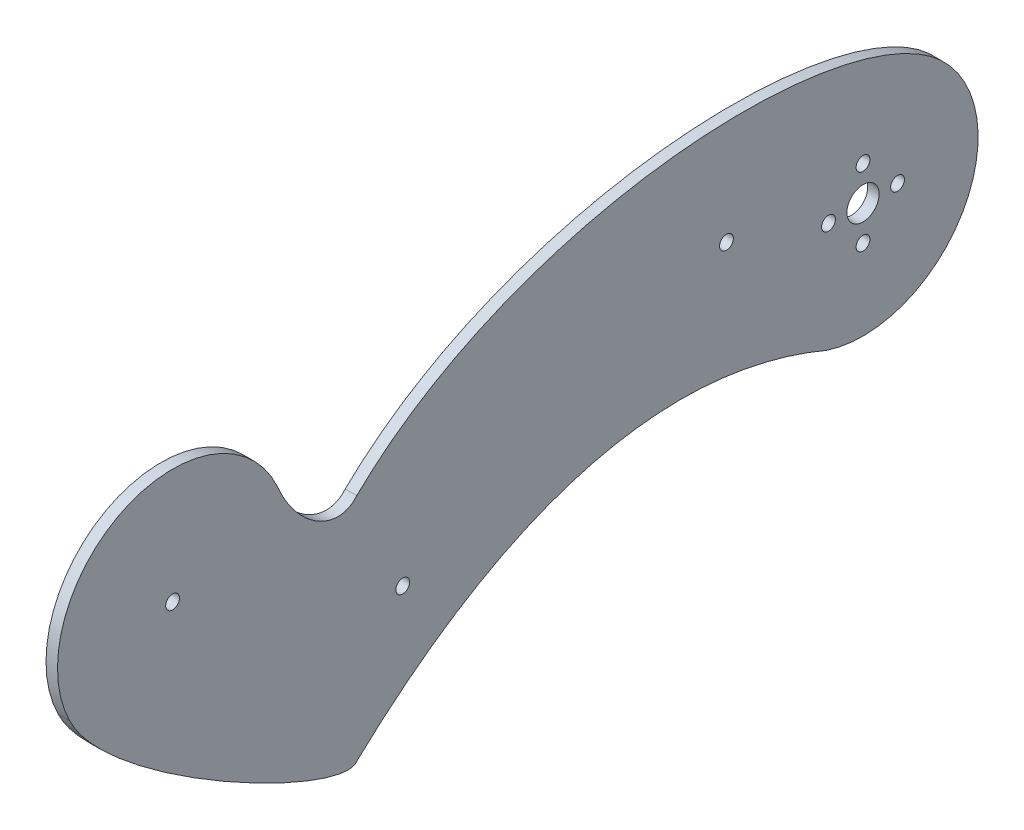
from build123d import *

# Parameters (mm, degrees)
CROQUIS1_R              = 1.5
CROQUIS1_R_2            = 3.5
SALIENTE_EXTRUIR1_DEPTH = 2.5


with BuildPart() as part:
    # Croquis1 → Saliente-Extruir1 (new body)
    with BuildSketch(Plane(origin=(0, 0, 0), x_dir=(0, 0, -1), z_dir=(1, 0, 0))):
        with BuildLine():
            ThreePointArc((-7.85459709, -23.73405369), (20.849117368, -13.795445081), (18.773557908, 16.509195119))
            add(Edge.make_bspline(
                [(-110, 0), (-73.673662094, 35.301314783), (0.482929837, 38.132802583), (18.773557908, 16.509195119)],
                knots=[0, 0, 0, 0, 1, 1, 1, 1], degree=3))
            add(Edge.make_bspline(
                [(-110, 0), (-114.062747325, -4.939612892), (-122.908484161, 0.095903893), (-127.189106422, 10.230500191)],
                knots=[0, 0, 0, 0, 1, 1, 1, 1], degree=3))
            ThreePointArc((-127.189106422, 10.230500191), (-160.738730688, 22.576086092), (-172.329956868, -11.241575792))
            add(Edge.make_bspline(
                [(-110, -50), (-113.363085111, -55.309529938), (-164.148966012, -28.400175315), (-172.329956868, -11.241575792)],
                knots=[0, 0, 0, 0, 1, 1, 1, 1], degree=3))
            add(Edge.make_bspline(
                [(-110, -50), (-84.313279839, -25.770287147), (-48.9234642, -6.39735454), (-7.85459709, -23.73405369)],
                knots=[0, 0, 0, 0, 1, 1, 1, 1], degree=3))
        make_face()
        with Locations((-150, 0)):
            Circle(CROQUIS1_R, mode=Mode.SUBTRACT)
        Circle(CROQUIS1_R_2, mode=Mode.SUBTRACT)
        with Locations((-29.661618982, 7.5)):
            Circle(CROQUIS1_R, mode=Mode.SUBTRACT)
        with Locations((-7.5, 0)):
            Circle(CROQUIS1_R, mode=Mode.SUBTRACT)
        with Locations((0, -7.5)):
            Circle(CROQUIS1_R, mode=Mode.SUBTRACT)
        with Locations((0, 7.5)):
            Circle(CROQUIS1_R, mode=Mode.SUBTRACT)
        with Locations((7.5, 0)):
            Circle(CROQUIS1_R, mode=Mode.SUBTRACT)
        with Locations((-100, -22)):
            Circle(CROQUIS1_R, mode=Mode.SUBTRACT)
    extrude(amount=SALIENTE_EXTRUIR1_DEPTH)


solid = part.part
